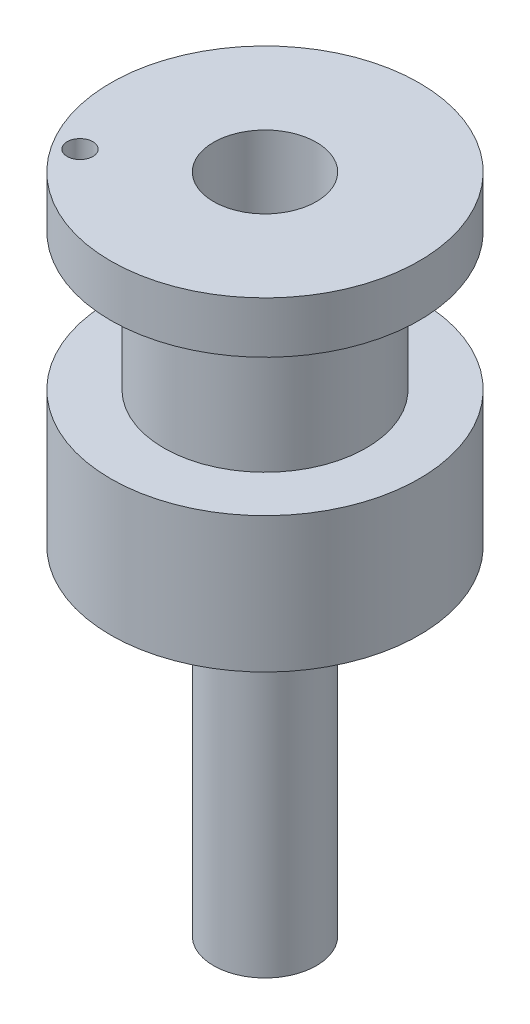
from build123d import *

# Parameters (mm, degrees)
SKETCH1_R           = 3
BOSS_EXTRUDE1_DEPTH = 19.7
SKETCH2_R           = 9
BOSS_EXTRUDE2_DEPTH = 7.9
SKETCH3_R           = 5.9
BOSS_EXTRUDE3_DEPTH = 8
SKETCH4_R           = 9
BOSS_EXTRUDE4_DEPTH = 3
SKETCH5_R           = 3
CUT_EXTRUDE1_DEPTH  = 9.6
SKETCH7_R           = 0.75
CUT_EXTRUDE2_DEPTH  = 10


with BuildPart() as part:
    # Sketch1 → Boss-Extrude1 (new body)
    with BuildSketch(Plane(origin=(0, 0, 0), x_dir=(1, 0, 0), z_dir=(0, 1, 0))):
        Circle(SKETCH1_R)
    extrude(amount=BOSS_EXTRUDE1_DEPTH)

    # Sketch2 → Boss-Extrude2 (add)
    with BuildSketch(Plane(origin=(0, 19.7, 0), x_dir=(1, 0, 0), z_dir=(0, 1, 0))):
        Circle(SKETCH2_R)
    extrude(amount=BOSS_EXTRUDE2_DEPTH)

    # Sketch3 → Boss-Extrude3 (add)
    with BuildSketch(Plane(origin=(0, 27.6, 0), x_dir=(1, 0, 0), z_dir=(0, 1, 0))):
        Circle(SKETCH3_R)
    extrude(amount=BOSS_EXTRUDE3_DEPTH)

    # Sketch4 → Boss-Extrude4 (add)
    with BuildSketch(Plane(origin=(0, 35.6, 0), x_dir=(1, 0, 0), z_dir=(0, 1, 0))):
        Circle(SKETCH4_R)
    extrude(amount=BOSS_EXTRUDE4_DEPTH)

    # Sketch5 → Cut-Extrude1 (cut)
    with BuildSketch(Plane(origin=(0, 38.6, 0), x_dir=(1, 0, 0), z_dir=(0, 1, 0))):
        Circle(SKETCH5_R)
    extrude(amount=-CUT_EXTRUDE1_DEPTH, mode=Mode.SUBTRACT)

    # Sketch7 → Cut-Extrude2 (cut)
    with BuildSketch(Plane(origin=(0, 38.6, 0), x_dir=(1, 0, 0), z_dir=(0, 1, 0))):
        with Locations((-6.55100535, -4.239956241)):
            Circle(SKETCH7_R)
    extrude(amount=-CUT_EXTRUDE2_DEPTH, mode=Mode.SUBTRACT)


solid = part.part
